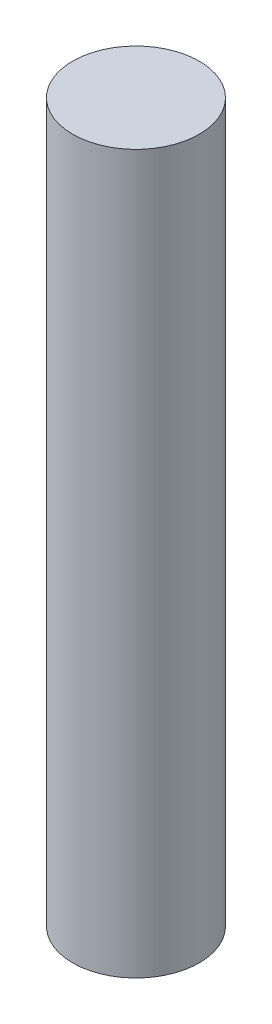
from build123d import *

# Parameters (mm, degrees)
SKETCH1_R           = 1.5
BOSS_EXTRUDE1_DEPTH = 17


with BuildPart() as part:
    # Sketch1 → Boss-Extrude1 (new body)
    with BuildSketch(Plane(origin=(0, 0, 0), x_dir=(1, 0, 0), z_dir=(0, 1, 0))):
        Circle(SKETCH1_R)
    extrude(amount=BOSS_EXTRUDE1_DEPTH)


solid = part.part
